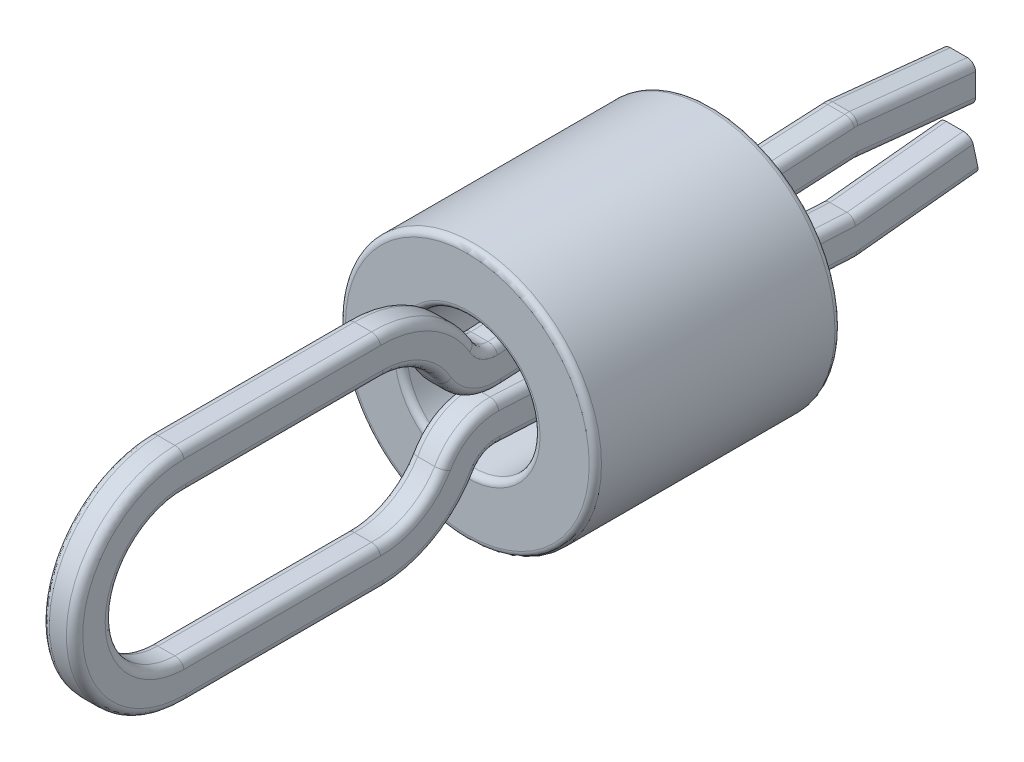
from build123d import *

# Parameters (mm, degrees)
SKETCH1_R          = 1.5875
SKETCH1_R_2        = 0.8255
PLASTIC_RING_DEPTH = 3.048
FILLET1_R          = 0.0762


with BuildPart() as part:
    # Sketch1 → Plastic-Ring (new body)
    with BuildSketch(Plane.XY):
        Circle(SKETCH1_R)
        Circle(SKETCH1_R_2, mode=Mode.SUBTRACT)
    extrude(amount=PLASTIC_RING_DEPTH)

    # Fillet1
    fillet1_edges = [part.edges().sort_by_distance(p)[0] for p in [
        (-1.5875, 0, 0),
        (-1.5875, 0, 3.048),
        (-0.8255, 0, 0),
        (-0.8255, 0, 3.048),
    ]]
    fillet(fillet1_edges, radius=FILLET1_R)


with BuildPart() as body_2:
    # Sweep3: sweep along a path in wire-bend
    with BuildLine(Plane(origin=(0, 0, 0), x_dir=(0, 0, -1), z_dir=(1, 0, 0))) as sweep3_path:
        Line((3.048, 0.381), (1.584583311, 0.532387933))
        ThreePointArc((1.584583311, 0.532387933), (1.574790193, 0.53301984), (1.564977521, 0.532893696))
        Line((1.564977521, 0.532893696), (-2.860117728, 0.3048))
        ThreePointArc((-2.860117728, 0.3048), (-3.136307543, 0.367482659), (-3.339131486, 0.56515))
        ThreePointArc((-3.339131486, 0.56515), (-3.75285, 0.978868514), (-4.318, 1.1303))
        Line((-4.318, 1.1303), (-6.7564, 1.1303))
        ThreePointArc((-6.7564, 1.1303), (-7.8867, 0), (-6.7564, -1.1303))
        Line((-6.7564, -1.1303), (-4.318, -1.1303))
        ThreePointArc((-4.318, -1.1303), (-3.75285, -0.978868514), (-3.339131486, -0.56515))
        ThreePointArc((-3.339131486, -0.56515), (-3.136307543, -0.367482659), (-2.860117728, -0.3048))
        Line((-2.860117728, -0.3048), (1.564977521, -0.532893696))
        ThreePointArc((1.564977521, -0.532893696), (1.574790193, -0.53301984), (1.584583311, -0.532387933))
        Line((1.584583311, -0.532387933), (3.048, -0.381))
    # wire-profile → Sweep3 (sweep)
    with BuildSketch(Plane.XY.offset(-3.048)):
        with BuildLine():
            Line((-0.10541, 0.6223), (0.10541, 0.6223))
            ThreePointArc((0.10541, 0.6223), (0.177252049, 0.592542049), (0.20701, 0.5207))
            Line((0.20701, 0.5207), (0.20701, 0.2413))
            ThreePointArc((0.20701, 0.2413), (0.177252049, 0.169457951), (0.10541, 0.1397))
            Line((0.10541, 0.1397), (-0.10541, 0.1397))
            ThreePointArc((-0.10541, 0.1397), (-0.177252049, 0.169457951), (-0.20701, 0.2413))
            Line((-0.20701, 0.2413), (-0.20701, 0.5207))
            ThreePointArc((-0.20701, 0.5207), (-0.177252049, 0.592542049), (-0.10541, 0.6223))
        make_face()
    sweep(path=sweep3_path.line)


solid = Compound([part.part, body_2.part])
